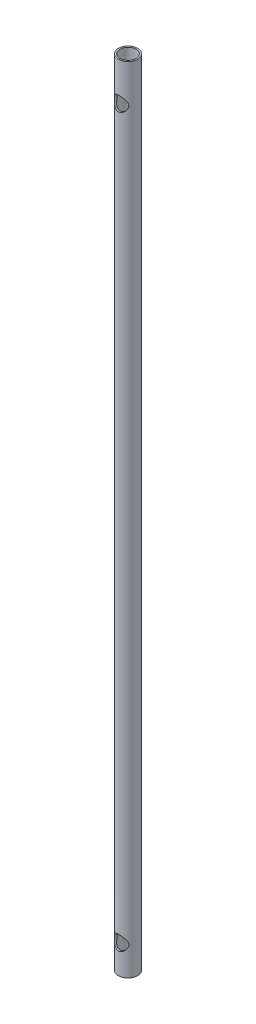
from build123d import *

# Parameters (mm, degrees)
SKETCH1_W                             = 1.016
SKETCH1_H                             = 527.05
F_3_8_0_375_DIAMETER_HOLE1_AT_2_COUNT = 2
F_3_8_0_375_DIAMETER_HOLE1_AT_2_PITCH = 482.6


with BuildPart() as part:
    # Sketch1 → Revolve1 (revolve)
    with BuildSketch(Plane.XY):
        with Locations((-5.842, -263.525)):
            Rectangle(SKETCH1_W, SKETCH1_H)
    revolve(axis=Axis((0, 0, 0), (0, -1, 0)))

    # Sketch3 → 3/8 (0.375) Diameter Hole1 (revolve, cut)
    with BuildSketch(Plane(origin=(0, -508, 0), x_dir=(0, 1, 0), z_dir=(1, 0, 0))):
        Polygon((0, 0), (0, 9.211598698), (4.7625, 6.35), (4.7625, 0), align=None)
    f_3_8_0_375_diameter_hole1 = revolve(axis=Axis((0, -508, -6.35), (0, 0, 1)), mode=Mode.SUBTRACT)

    # 3/8 (0.375) Diameter Hole1 at 2: 3/8 (0.375) Diameter Hole1 ×2
    with Locations(*[(0, i * F_3_8_0_375_DIAMETER_HOLE1_AT_2_PITCH, 0) for i in range(1, F_3_8_0_375_DIAMETER_HOLE1_AT_2_COUNT)]):
        add(f_3_8_0_375_diameter_hole1, mode=Mode.SUBTRACT)


solid = part.part
